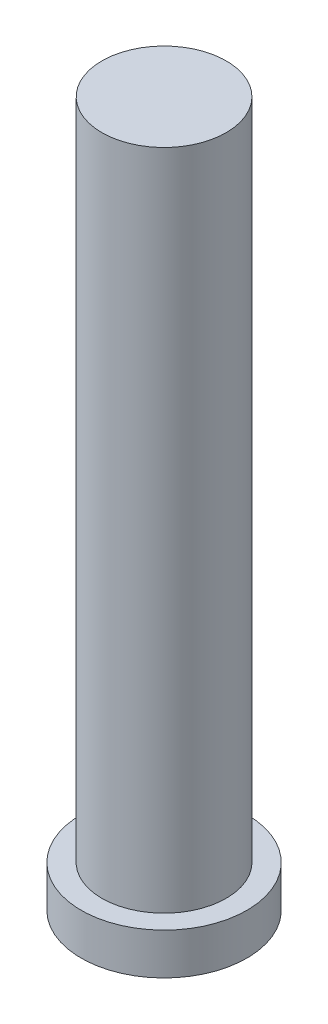
from build123d import *

# Parameters (mm, degrees)
SKETCH_2_R      = 0.75
EXTRUDE_1_DEPTH = 8
SKETCH_3_R      = 1
EXTRUDE_2_DEPTH = 0.5


with BuildPart() as part:
    # 草图2 → 凸台-拉伸1 (new body)
    with BuildSketch(Plane(origin=(0, 0, 0), x_dir=(1, 0, 0), z_dir=(0, 1, 0))):
        Circle(SKETCH_2_R)
    extrude(amount=EXTRUDE_1_DEPTH)

    # 草图3 → 凸台-拉伸2 (add)
    with BuildSketch(Plane.XZ):
        Circle(SKETCH_3_R)
    extrude(amount=EXTRUDE_2_DEPTH)


solid = part.part
